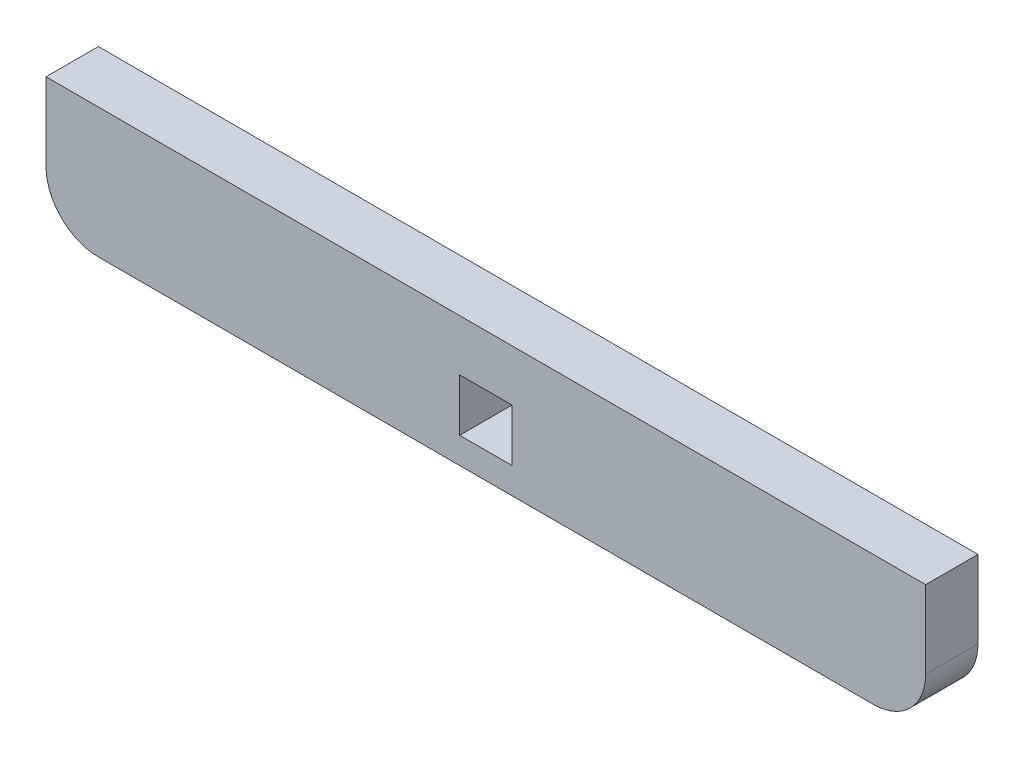
from build123d import *

# Parameters (mm, degrees)
SKETCH1_W           = 3.175
SKETCH1_H           = 3.175
BOSS_EXTRUDE1_DEPTH = 3.175


with BuildPart() as part:
    # Sketch1 → Boss-Extrude1 (new body)
    with BuildSketch(Plane.XY):
        with BuildLine():
            Line((10.16, -2.286), (63.5, -2.286))
            Line((63.5, -2.286), (63.5, -6.985))
            ThreePointArc((63.5, -6.985), (62.57006403, -9.23006403), (60.325, -10.16))
            Line((60.325, -10.16), (13.335, -10.16))
            ThreePointArc((13.335, -10.16), (11.08993597, -9.23006403), (10.16, -6.985))
            Line((10.16, -6.985), (10.16, -2.286))
        make_face()
        with Locations((36.83, -6.985)):
            Rectangle(SKETCH1_W, SKETCH1_H, mode=Mode.SUBTRACT)
    extrude(amount=BOSS_EXTRUDE1_DEPTH)


solid = part.part
